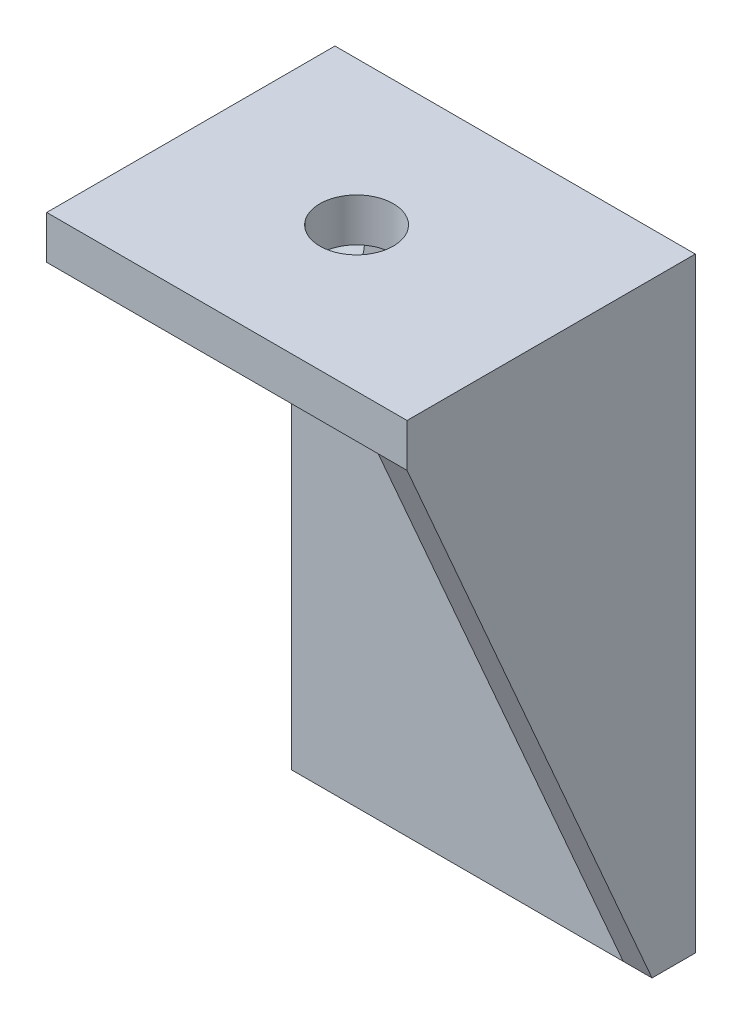
from build123d import *

# Parameters (mm, degrees)
SKETCH1_W           = 23
SKETCH1_H           = 42.000000074
SKETCH1_R           = 2.05
BOSS_EXTRUDE1_DEPTH = 3
SKETCH2_W           = 23
SKETCH2_H           = 17
SKETCH2_R           = 2.55
BOSS_EXTRUDE2_DEPTH = 3
BOSS_EXTRUDE3_DEPTH = 2


with BuildPart() as part:
    # Sketch1 → Boss-Extrude1 (new body)
    with BuildSketch(Plane.XY):
        with Locations((11.5, 21.000000037)):
            Rectangle(SKETCH1_W, SKETCH1_H)
        with Locations((17.34, 12.13)):
            Circle(SKETCH1_R, mode=Mode.SUBTRACT)
        with Locations((2.99, 34.1)):
            Circle(SKETCH1_R, mode=Mode.SUBTRACT)
    extrude(amount=BOSS_EXTRUDE1_DEPTH)

    # Sketch2 → Boss-Extrude2 (add)
    with BuildSketch(Plane(origin=(0, 42.000000074, 0), x_dir=(1, 0, 0), z_dir=(0, 1, 0))):
        with Locations((11.5, -11.5)):
            Rectangle(SKETCH2_W, SKETCH2_H)
        with Locations((11.5, -10)):
            Circle(SKETCH2_R, mode=Mode.SUBTRACT)
    extrude(amount=-BOSS_EXTRUDE2_DEPTH)

    # Sketch3 → Boss-Extrude3 (add)
    with BuildSketch(Plane(origin=(23, 0, 0), x_dir=(0, 0, -1), z_dir=(1, 0, 0))):
        Polygon((-20, 39.000000074), (-3, 0), (0, 0), (0, 42.000000074), (-20, 42.000000074), align=None)
    extrude(amount=BOSS_EXTRUDE3_DEPTH)


solid = part.part
